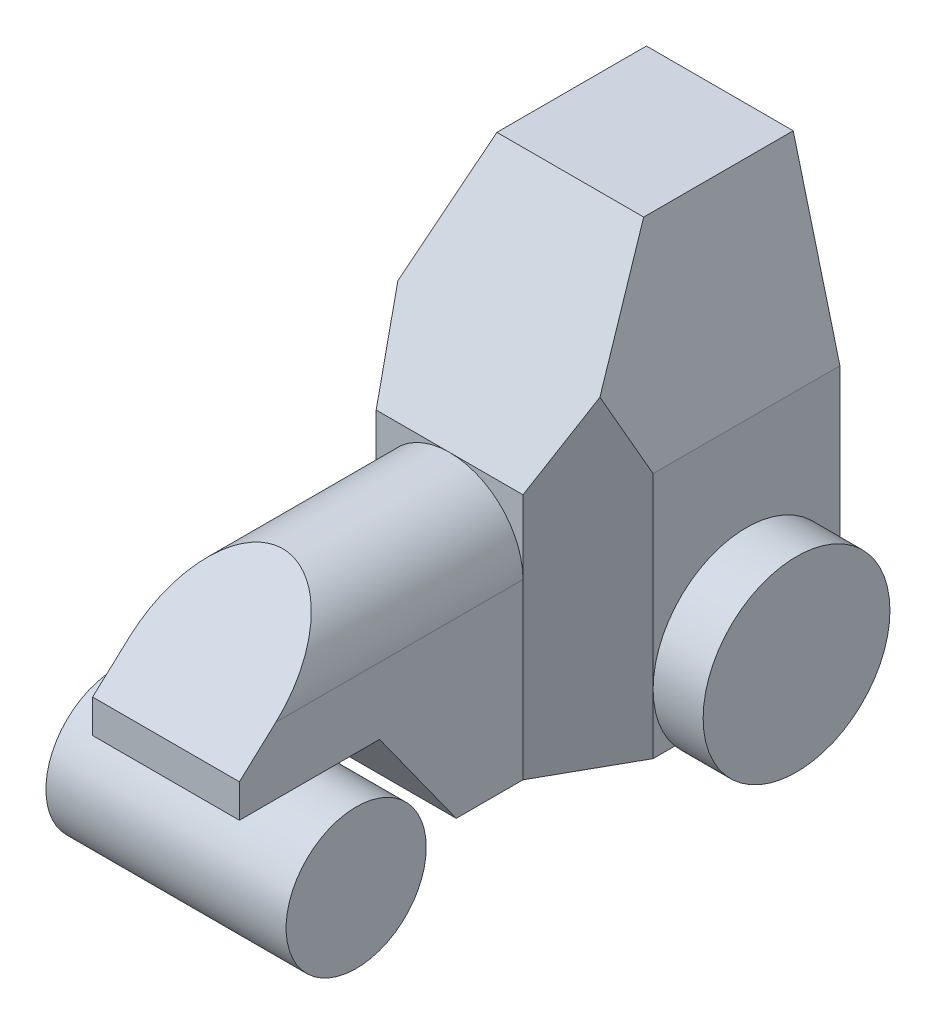
from build123d import *

# Parameters (mm, degrees)
SKETCH1_W           = 72
SKETCH1_H           = 81
BOSS_EXTRUDE1_DEPTH = 128
CUT_EXTRUDE1_DEPTH  = 129
CUT_EXTRUDE2_DEPTH  = 82
CUT_EXTRUDE3_DEPTH  = 128
SKETCH5_R           = 28
BOSS_EXTRUDE2_DEPTH = 15
SKETCH6_R           = 28
BOSS_EXTRUDE3_DEPTH = 15
BOSS_EXTRUDE4_DEPTH = 85
CUT_EXTRUDE4_DEPTH  = 85
SKETCH10_R          = 21
BOSS_EXTRUDE5_DEPTH = 72


with BuildPart() as part:
    # Sketch1 → Boss-Extrude1 (new body)
    with BuildSketch(Plane(origin=(0, 0, 0), x_dir=(1, 0, 0), z_dir=(0, 1, 0))):
        with Locations((36, 40.5)):
            Rectangle(SKETCH1_W, SKETCH1_H)
    extrude(amount=BOSS_EXTRUDE1_DEPTH)

    # Sketch2 → Cut-Extrude1 (cut, through all)
    with BuildSketch(Plane(origin=(0, 128, 0), x_dir=(1, 0, 0), z_dir=(0, 1, 0))):
        Polygon((72, 25), (58, 0), (72, 0), align=None)
        Polygon((14, 0), (0, 0), (0, 25), align=None)
    extrude(amount=-CUT_EXTRUDE1_DEPTH, mode=Mode.SUBTRACT)

    # Sketch3 → Cut-Extrude2 (cut, through all)
    with BuildSketch(Plane.XY):
        Polygon((58, 128), (72, 74), (72, 128), align=None)
        Polygon((14, 128), (0, 74), (0, 128), align=None)
    extrude(amount=-CUT_EXTRUDE2_DEPTH, mode=Mode.SUBTRACT)

    # Sketch4 → Cut-Extrude3 (cut)
    with BuildSketch(Plane(origin=(72, 0, 0), x_dir=(0, 0, -1), z_dir=(1, 0, 0))):
        Polygon((0, 74), (36.18010503, 128), (0, 128), align=None)
    extrude(amount=-CUT_EXTRUDE3_DEPTH, mode=Mode.SUBTRACT)

    # Sketch5 → Boss-Extrude2 (add)
    with BuildSketch(Plane(origin=(72, 0, 0), x_dir=(0, 0, -1), z_dir=(1, 0, 0))):
        with Locations((53, 18)):
            Circle(SKETCH5_R)
    extrude(amount=BOSS_EXTRUDE2_DEPTH)

    # Sketch6 → Boss-Extrude3 (add)
    with BuildSketch(Plane.ZY):
        with Locations(Location((-53, 18, 0), (0, 0, 180))):  # turned: the seam where the file's is
            Circle(SKETCH6_R)
    extrude(amount=BOSS_EXTRUDE3_DEPTH)

    # Sketch8 → Boss-Extrude4 (add)
    with BuildSketch(Plane.XY):
        with BuildLine():
            Line((14, 52), (14, 0))
            Line((14, 0), (58, 0))
            Line((58, 0), (58, 52))
            ThreePointArc((58, 52), (36, 74), (14, 52))
        make_face()
    extrude(amount=BOSS_EXTRUDE4_DEPTH)

    # Sketch9 → Cut-Extrude4 (cut)
    with BuildSketch(Plane(origin=(58, 0, 0), x_dir=(0, 0, -1), z_dir=(1, 0, 0))):
        Polygon((-85, 32), (-43, 32), (-20, 0), (-85, 0), align=None)
        Polygon((-85, 42), (-50, 74), (-85, 74), align=None)
    extrude(amount=-CUT_EXTRUDE4_DEPTH, mode=Mode.SUBTRACT)


with BuildPart() as body_2:
    # Sketch10 → Boss-Extrude5 (new body)
    with BuildSketch(Plane(origin=(72, 0, 0), x_dir=(0, 0, -1), z_dir=(1, 0, 0))):
        with Locations((-64, 11)):
            Circle(SKETCH10_R)
    extrude(amount=-BOSS_EXTRUDE5_DEPTH)


solid = Compound([part.part, body_2.part])
